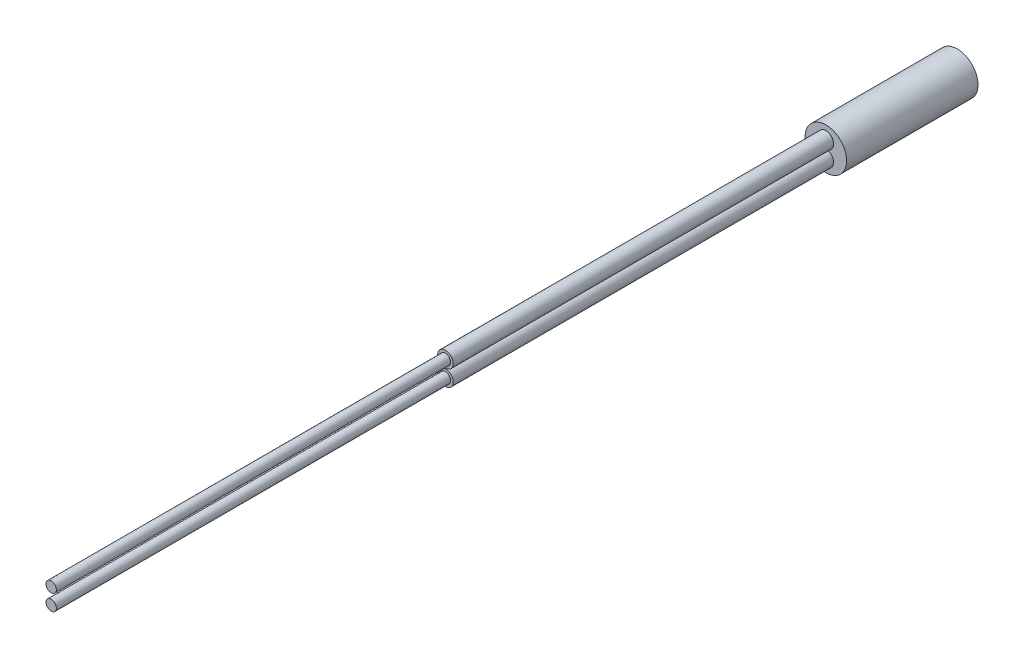
from build123d import *

# Parameters (mm, degrees)
CROQUIS1_R                   = 3
SALIENTE_EXTRUIR1_DEPTH      = 18
SALIENTE_EXTRUIR2_DEPTH      = 21.5
SALIENTE_EXTRUIR2_DEPTH_BACK = 1.5
CROQUIS1_2_R                 = 3
CROQUIS3_R                   = 3
CORTAR_EXTRUIR1_DEPTH        = 4
CROQUIS9_R                   = 1.125
SALIENTE_EXTRUIR3_DEPTH      = 55
CROQUIS10_R                  = 0.75
SALIENTE_EXTRUIR4_DEPTH      = 112


with BuildPart() as part:
    # Croquis1 → Saliente-Extruir1 (new body)
    with BuildSketch(Plane.XY):
        Circle(CROQUIS1_R)
    extrude(amount=SALIENTE_EXTRUIR1_DEPTH)

    # Croquis1_2 → Saliente-Extruir2 (add, two sides: drawn at the far end of the back side and taken through both)
    with BuildSketch(Plane.XY.offset(-SALIENTE_EXTRUIR2_DEPTH_BACK)):
        Circle(CROQUIS1_2_R)
    extrude(amount=SALIENTE_EXTRUIR2_DEPTH + SALIENTE_EXTRUIR2_DEPTH_BACK)

    # Croquis3 → Cortar-Extruir1 (cut)
    with BuildSketch(Plane(origin=(0, 0, -1.5), x_dir=(-1, 0, 0), z_dir=(0, 0, -1))):
        Circle(CROQUIS3_R)
    extrude(amount=-CORTAR_EXTRUIR1_DEPTH, mode=Mode.SUBTRACT)

    # Croquis9 → Saliente-Extruir3 (add)
    with BuildSketch(Plane.XY.offset(21.5)):
        with Locations((0, -1.15)):
            Circle(CROQUIS9_R)
        with Locations((0, 1.15)):
            Circle(CROQUIS9_R)
    extrude(amount=SALIENTE_EXTRUIR3_DEPTH)

    # Croquis10 → Saliente-Extruir4 (add)
    with BuildSketch(Plane.XY.offset(21.5)):
        with Locations((0, -1.15)):
            Circle(CROQUIS10_R)
        with Locations((0, 1.15)):
            Circle(CROQUIS10_R)
    extrude(amount=SALIENTE_EXTRUIR4_DEPTH)


solid = part.part
